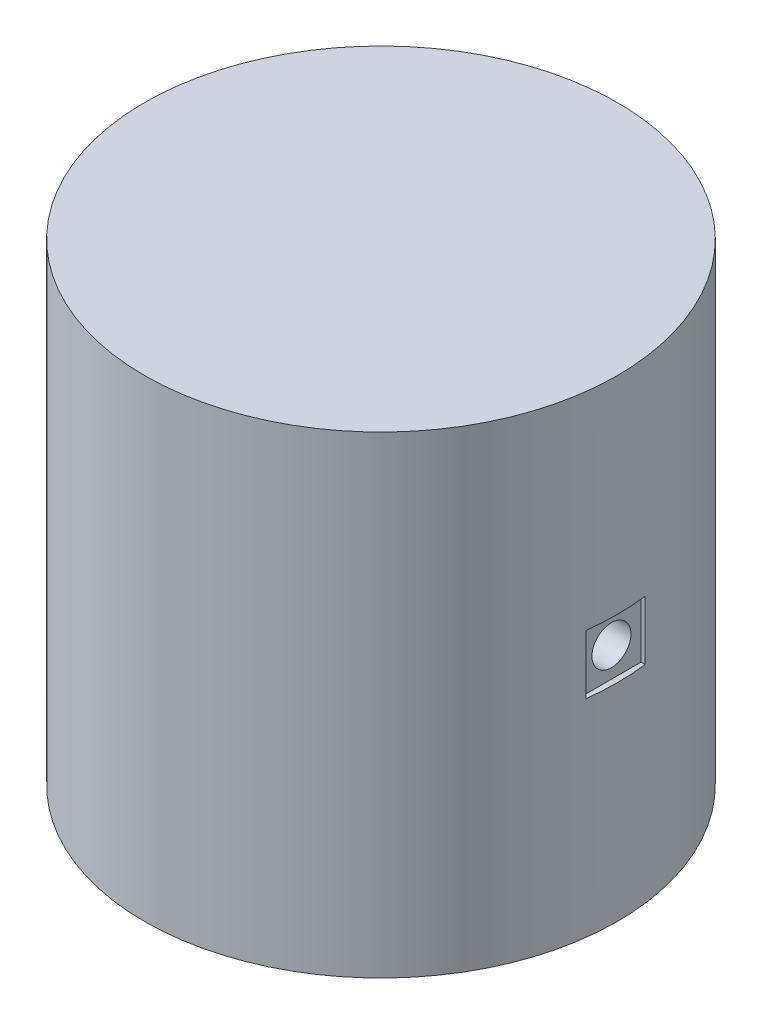
from build123d import *

# Parameters (mm, degrees)
SKETCH1_R                  = 20
BOSS_EXTRUDE1_DEPTH        = 40
SKETCH3_R                  = 4
CUT_EXTRUDE1_DEPTH         = 30
M4X0_7_TAPPED_HOLE1_REACH  = 50.99
M4X0_7_TAPPED_HOLE1_BORE_R = 1.65
SKETCH4_W                  = 5
SKETCH4_H                  = 5
CUT_EXTRUDE2_DEPTH         = 0.5


with BuildPart() as part:
    # Sketch1 → Boss-Extrude1 (new body)
    with BuildSketch(Plane(origin=(0, 0, 0), x_dir=(1, 0, 0), z_dir=(0, 1, 0))):
        with Locations(Location((0, 0, 0), (0, 0, 270))):
            Circle(SKETCH1_R)
    extrude(amount=BOSS_EXTRUDE1_DEPTH)

    # Sketch3 → Cut-Extrude1 (cut)
    with BuildSketch(Plane(origin=(0, 0, -20), x_dir=(-1, 0, 0), z_dir=(0, 0, -1))):
        with Locations((0, 20)):
            Circle(SKETCH3_R)
    extrude(amount=-CUT_EXTRUDE1_DEPTH, mode=Mode.SUBTRACT)

    # M4x0.7 Tapped Hole1 bore (on position points) → M4x0.7 Tapped Hole1 (cut, up to next)
    with BuildSketch(Plane(origin=(20, 20, 0), x_dir=(0, 0, 1), z_dir=(1, 0, 0)), mode=Mode.PRIVATE) as m4x0_7_tapped_hole1_sk1:
        Circle(M4X0_7_TAPPED_HOLE1_BORE_R)
    m4x0_7_tapped_hole1_tool1 = extrude(m4x0_7_tapped_hole1_sk1.sketch, amount=-M4X0_7_TAPPED_HOLE1_REACH, mode=Mode.PRIVATE) & part.part
    add(m4x0_7_tapped_hole1_tool1.solids().sort_by_distance((20, 20, 0))[0], mode=Mode.SUBTRACT)

    # Sketch4 → Cut-Extrude2 (cut)
    with BuildSketch(Plane(origin=(20, 0, 0), x_dir=(0, 0, -1), z_dir=(1, 0, 0))):
        with Locations((0, 20)):
            Rectangle(SKETCH4_W, SKETCH4_H)
    extrude(amount=-CUT_EXTRUDE2_DEPTH, mode=Mode.SUBTRACT)


solid = part.part
